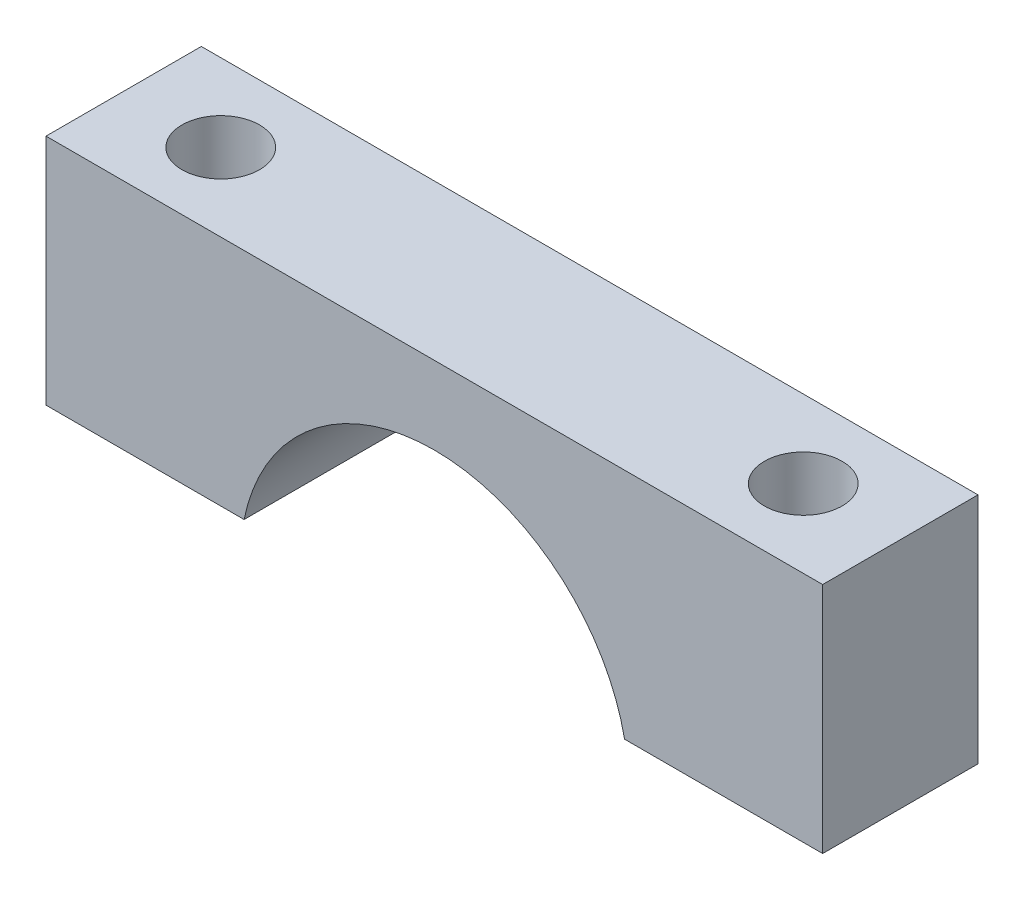
from build123d import *

# Parameters (mm, degrees)
EXTRUDE1_DEPTH = 4
SKETCH2_R      = 1
EXTRUDE2_DEPTH = 7


with BuildPart() as part:
    # Sketch1 → Extrude1 (new body)
    with BuildSketch(Plane.XY):
        with BuildLine():
            Line((4.898979486, -3), (10, -3))
            Line((10, -3), (10, 3))
            Line((10, 3), (-10, 3))
            Line((-10, 3), (-10, -3))
            Line((-10, -3), (-4.898979486, -3))
            ThreePointArc((-4.898979486, -3), (0, 1), (4.898979486, -3))
        make_face()
    extrude(amount=EXTRUDE1_DEPTH)

    # Sketch2 → Extrude2 (cut, through all)
    with BuildSketch(Plane.XZ.offset(3)):
        with Locations((-7.5, 2)):
            Circle(SKETCH2_R)
    extrude2 = extrude(amount=-EXTRUDE2_DEPTH, mode=Mode.SUBTRACT)

    # Mirror1: Extrude2 across plane
    add(extrude2.mirror(Plane(origin=(0, 0, 0), x_dir=(0, 0, 1), z_dir=(1, 0, 0))), mode=Mode.SUBTRACT)


solid = part.part
